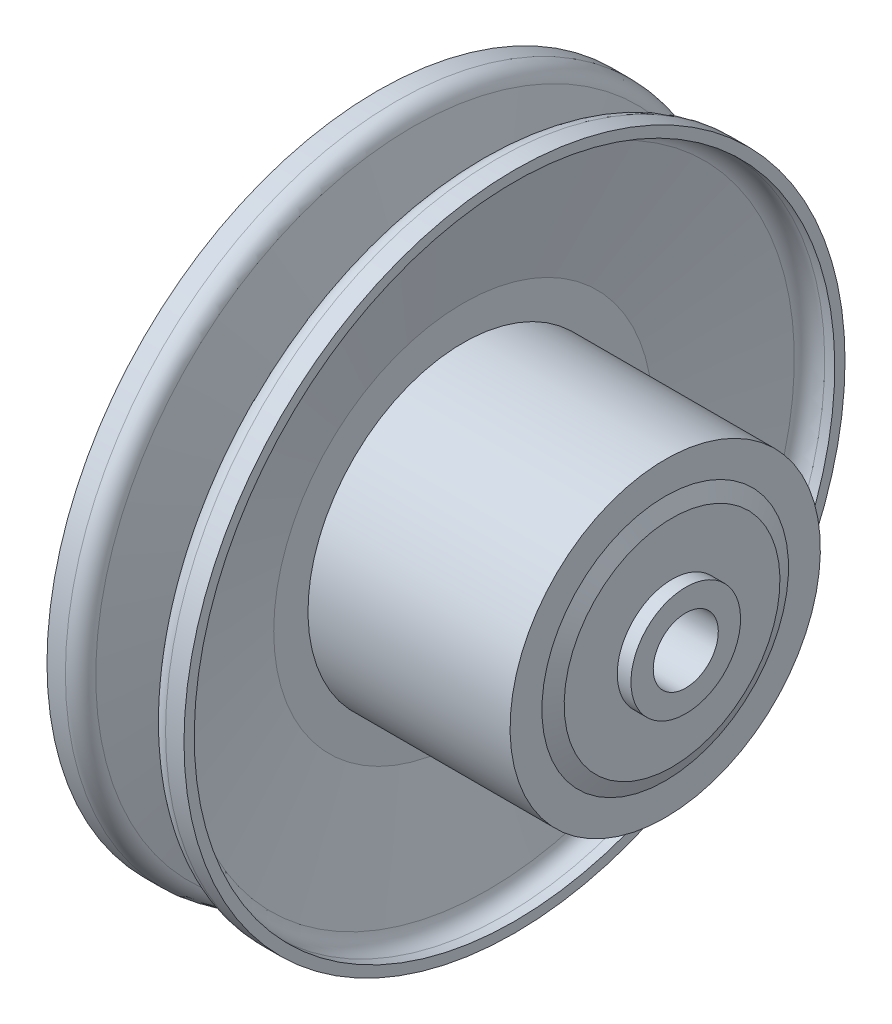
from build123d import *

# Parameters (mm, degrees)
FILLET_1_R      = 5
EXTRUDE_START   = -12
SKETCH_2_W      = 5
SKETCH_2_H      = 5
EXTRUDE_1_DEPTH = 35


with BuildPart() as part:
    # Эскиз1 → Повернуть1 (revolve)
    with BuildSketch(Plane.XY):
        Polygon((45, 9.5), (-40, 9.5), (-40, 14), (-35, 14), (-35, 45.3), (-30, 45.3), (-30, 55.3), (-38, 93.5), (-45, 93.5), (-45, 96.5), (-35.56319052, 96.5), (-27, 55.610765269), (-27, 35), (-23, 35), (-23, 55.610765269), (-14.43680948, 96.5), (-5, 96.5), (-5, 93.5), (-12, 93.5), (-20, 55.3), (-20, 45.3), (39, 45.3), (39, 36), (41, 31.5), (41, 16), (45, 16), align=None)
    revolve(axis=Axis((-45, 0, 0), (1, 0, 0)))

    # Скругление1
    fillet_1_edges = [part.edges().sort_by_distance(p)[0] for p in [
        (-38, -93.5, 0),
        (-35.56319052, -96.5, 0),
        (-14.43680948, -96.5, 0),
        (-12, -93.5, 0),
    ]]
    fillet(fillet_1_edges, radius=FILLET_1_R)

    # Эскиз2 → Бобышка-Вытянуть1 (add)
    with BuildSketch(Plane.ZY.offset(40).offset(EXTRUDE_START)):
        with Locations((0, 9.5)):
            Rectangle(SKETCH_2_W, SKETCH_2_H)
    extrude(amount=-EXTRUDE_1_DEPTH)


solid = part.part
